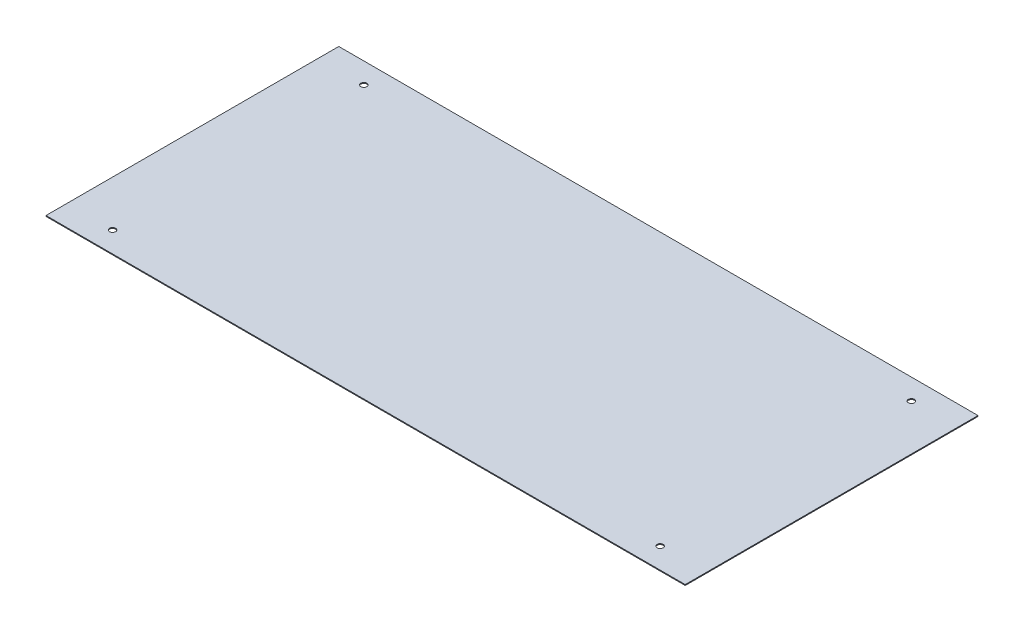
from build123d import *

# Parameters (mm, degrees)
SKETCH2_W           = 738
SKETCH2_H           = 338
SKETCH2_R           = 3.5
BOSS_EXTRUDE1_DEPTH = 1


with BuildPart() as part:
    # Sketch2 → Boss-Extrude1 (new body)
    with BuildSketch(Plane(origin=(0, 0, 0), x_dir=(1, 0, 0), z_dir=(0, 1, 0))):
        Rectangle(SKETCH2_W, SKETCH2_H)
        with Locations((-316.061908403, 145)):
            Circle(SKETCH2_R, mode=Mode.SUBTRACT)
        with Locations((-316.061908403, -145)):
            Circle(SKETCH2_R, mode=Mode.SUBTRACT)
        with Locations((316.061908403, -145)):
            Circle(SKETCH2_R, mode=Mode.SUBTRACT)
        with Locations((316.061908403, 145)):
            Circle(SKETCH2_R, mode=Mode.SUBTRACT)
    extrude(amount=BOSS_EXTRUDE1_DEPTH)


solid = part.part
